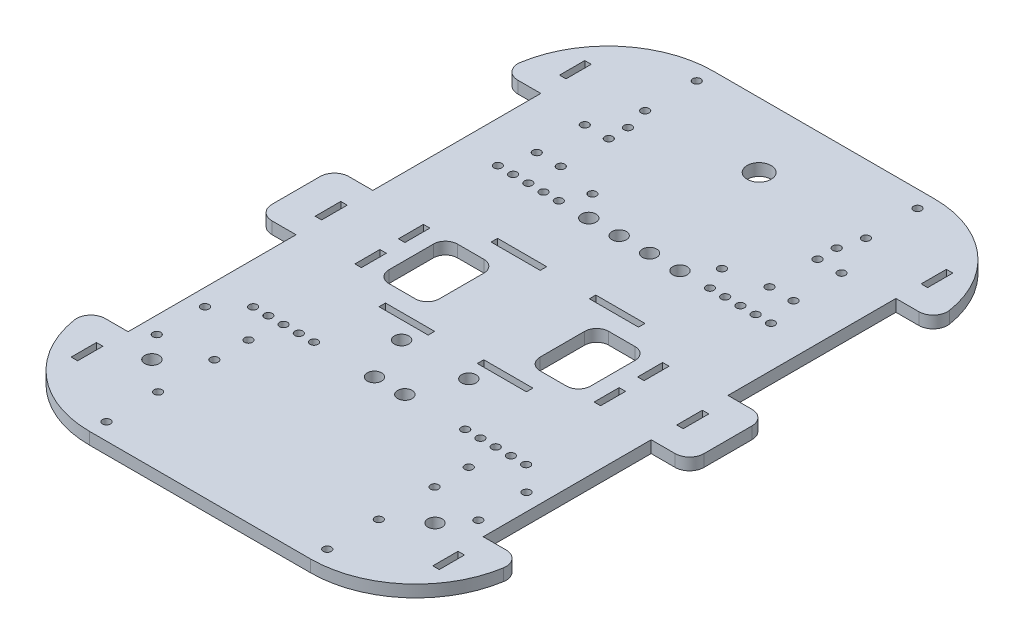
from build123d import *

# Parameters (mm, degrees)
SKETCH2_W           = 2.7
SKETCH2_H           = 10.51
SKETCH2_H_2         = 10.666666666
BOSS_EXTRUDE4_DEPTH = 5
SKETCH5_R           = 1.65
SKETCH5_R_2         = 3
SKETCH5_R_3         = 5
SKETCH5_W           = 20.48
SKETCH5_H           = 2.7
SKETCH5_W_2         = 2.7
SKETCH5_H_2         = 10.42
CUT_EXTRUDE1_DEPTH  = 6


with BuildPart() as part:
    # Sketch2 → Boss-Extrude4 (new body)
    with BuildSketch(Plane(origin=(0, 0, 0), x_dir=(1, 0, 0), z_dir=(0, 1, 0))):
        with BuildLine():
            Line((46, -130), (-46, -130))
            ThreePointArc((-46, -130), (-74.550970119, -119.478980051), (-89.448061775, -92.947368421))
            ThreePointArc((-89.448061775, -92.947368421), (-88.08864154, -88.106685893), (-83.523326079, -86))
            Line((-83.523326079, -86), (-74, -86))
            Line((-74, -86), (-74, -16))
            Line((-74, -16), (-84, -16))
            ThreePointArc((-84, -16), (-88.242640687, -14.242640687), (-90, -10))
            Line((-90, -10), (-90, 10))
            ThreePointArc((-90, 10), (-88.242640687, 14.242640687), (-84, 16))
            Line((-84, 16), (-74, 16))
            Line((-74, 16), (-74, 86))
            Line((-74, 86), (-83.523326079, 86))
            ThreePointArc((-83.523326079, 86), (-88.08864154, 88.106685893), (-89.448061775, 92.947368421))
            ThreePointArc((-89.448061775, 92.947368421), (-74.550970119, 119.478980051), (-46, 130))
            Line((-46, 130), (46, 130))
            ThreePointArc((46, 130), (74.550970119, 119.478980051), (89.448061775, 92.947368421))
            ThreePointArc((89.448061775, 92.947368421), (88.08864154, 88.106685893), (83.523326079, 86))
            Line((83.523326079, 86), (74, 86))
            Line((74, 86), (74, 16))
            Line((74, 16), (84, 16))
            ThreePointArc((84, 16), (88.242640687, 14.242640687), (90, 10))
            Line((90, 10), (90, -10))
            ThreePointArc((90, -10), (88.242640687, -14.242640687), (84, -16))
            Line((84, -16), (74, -16))
            Line((74, -16), (74, -86))
            Line((74, -86), (83.523326079, -86))
            ThreePointArc((83.523326079, -86), (88.08864154, -88.106685893), (89.448061775, -92.947368421))
            ThreePointArc((89.448061775, -92.947368421), (74.550970119, -119.478980051), (46, -130))
        make_face()
        with Locations((-75.35, 101.765)):
            Rectangle(SKETCH2_W, SKETCH2_H, mode=Mode.SUBTRACT)
        with Locations((75.35, 101.765)):
            Rectangle(SKETCH2_W, SKETCH2_H, mode=Mode.SUBTRACT)
        with Locations((75.35, -101.765)):
            Rectangle(SKETCH2_W, SKETCH2_H, mode=Mode.SUBTRACT)
        with Locations((-75.35, -101.765)):
            Rectangle(SKETCH2_W, SKETCH2_H, mode=Mode.SUBTRACT)
        with Locations((-75.35, 0)):
            Rectangle(SKETCH2_W, SKETCH2_H_2, mode=Mode.SUBTRACT)
        with Locations((75.35, 0)):
            Rectangle(SKETCH2_W, SKETCH2_H_2, mode=Mode.SUBTRACT)
    extrude(amount=BOSS_EXTRUDE4_DEPTH)

    # Sketch5 → Cut-Extrude1 (cut, through all)
    with BuildSketch(Plane(origin=(0, 5, 0), x_dir=(1, 0, 0), z_dir=(0, 1, 0))):
        with Locations((-56.9, -51)):
            Circle(SKETCH5_R)
        with Locations((-50.55, -51)):
            Circle(SKETCH5_R)
        with Locations((-44.2, -51)):
            Circle(SKETCH5_R)
        with Locations((-37.85, -51)):
            Circle(SKETCH5_R)
        with Locations((-31.5, -51)):
            Circle(SKETCH5_R)
        with Locations((31.5, -51)):
            Circle(SKETCH5_R)
        with Locations((37.85, -51)):
            Circle(SKETCH5_R)
        with Locations((44.2, -51)):
            Circle(SKETCH5_R)
        with Locations((50.55, -51)):
            Circle(SKETCH5_R)
        with Locations((56.9, -51)):
            Circle(SKETCH5_R)
        with Locations((56.9, 51)):
            Circle(SKETCH5_R)
        with Locations((50.55, 51)):
            Circle(SKETCH5_R)
        with Locations((44.2, 51)):
            Circle(SKETCH5_R)
        with Locations((37.85, 51)):
            Circle(SKETCH5_R)
        with Locations((31.5, 51)):
            Circle(SKETCH5_R)
        with Locations((-31.5, 51)):
            Circle(SKETCH5_R)
        with Locations((-37.85, 51)):
            Circle(SKETCH5_R)
        with Locations((-44.2, 51)):
            Circle(SKETCH5_R)
        with Locations((-50.55, 51)):
            Circle(SKETCH5_R)
        with Locations((-56.9, 51)):
            Circle(SKETCH5_R)
        with Locations((-14, -32)):
            Circle(SKETCH5_R_2)
        with Locations((14, -32)):
            Circle(SKETCH5_R_2)
        with Locations((19, 51)):
            Circle(SKETCH5_R_2)
        with Locations((-19, 51)):
            Circle(SKETCH5_R_2)
        with Locations((-53.5, 83.83)):
            Circle(SKETCH5_R)
        with Locations((-53.5, 63.83)):
            Circle(SKETCH5_R)
        with Locations((-43.5, 63.83)):
            Circle(SKETCH5_R)
        with Locations((-43.5, 83.83)):
            Circle(SKETCH5_R)
        with Locations((43.5, 63.83)):
            Circle(SKETCH5_R)
        with Locations((53.5, 63.83)):
            Circle(SKETCH5_R)
        with Locations((43.5, 83.83)):
            Circle(SKETCH5_R)
        with Locations((53.5, 83.83)):
            Circle(SKETCH5_R)
        with Locations((-46, 123)):
            Circle(SKETCH5_R)
        with Locations((-46, 101.5)):
            Circle(SKETCH5_R)
        with Locations((46, 101.5)):
            Circle(SKETCH5_R)
        with Locations((46, 123)):
            Circle(SKETCH5_R)
        with Locations((-67, -60.960027583)):
            Circle(SKETCH5_R)
        with Locations((-45.897115189, -63.923125828)):
            Circle(SKETCH5_R)
        with Locations((-67, -81.039972417)):
            Circle(SKETCH5_R)
        with Locations((-45.897115189, -78.156819007)):
            Circle(SKETCH5_R)
        with Locations((45.897115189, -63.923125828)):
            Circle(SKETCH5_R)
        with Locations((45.897115189, -78.156819007)):
            Circle(SKETCH5_R)
        with Locations((67, -81.039972417)):
            Circle(SKETCH5_R)
        with Locations((67, -60.960027583)):
            Circle(SKETCH5_R)
        with Locations((46, -123)):
            Circle(SKETCH5_R)
        with Locations((46, -101.5)):
            Circle(SKETCH5_R)
        with Locations((-46, -101.5)):
            Circle(SKETCH5_R)
        with Locations((-46, -123)):
            Circle(SKETCH5_R)
        with Locations((-27, 60.5)):
            Circle(SKETCH5_R)
        with Locations((27, 60.5)):
            Circle(SKETCH5_R)
        with Locations((-43.5, 91.83)):
            Circle(SKETCH5_R)
        with Locations((43.5, 91.83)):
            Circle(SKETCH5_R)
        with Locations((-6.333333333, 51)):
            Circle(SKETCH5_R_2)
        with Locations((6.333333333, 51)):
            Circle(SKETCH5_R_2)
        with Locations((0, 103)):
            Circle(SKETCH5_R_3)
        with Locations((59, -91.08)):
            Circle(SKETCH5_R_2)
        with Locations((-59, -91.08)):
            Circle(SKETCH5_R_2)
        with Locations((-6.333333333, -51)):
            Circle(SKETCH5_R_2)
        with Locations((6.333333333, -51)):
            Circle(SKETCH5_R_2)
        with Locations((20.48, -23.35)):
            Rectangle(SKETCH5_W, SKETCH5_H)
        with Locations((-20.48, -23.35)):
            Rectangle(SKETCH5_W, SKETCH5_H)
        with Locations((20.48, 23.35)):
            Rectangle(SKETCH5_W, SKETCH5_H)
        with Locations((-20.48, 23.35)):
            Rectangle(SKETCH5_W, SKETCH5_H)
        with Locations((49.85, -9.07)):
            Rectangle(SKETCH5_W_2, SKETCH5_H_2)
        with Locations((49.85, 9.07)):
            Rectangle(SKETCH5_W_2, SKETCH5_H_2)
        with Locations((-49.85, 9.07)):
            Rectangle(SKETCH5_W_2, SKETCH5_H_2)
        with Locations((-49.85, -9.07)):
            Rectangle(SKETCH5_W_2, SKETCH5_H_2)
        with BuildLine():
            Line((37.006010734, 14.28), (26.003005367, 14.28))
            ThreePointArc((26.003005367, 14.28), (22.467471461, 12.815533906), (21.003005367, 9.28))
            Line((21.003005367, 9.28), (21.003005367, -7.14))
            Line((21.003005367, -7.14), (21.003005367, -9.28))
            ThreePointArc((21.003005367, -9.28), (22.467471461, -12.815533906), (26.003005367, -14.28))
            Line((26.003005367, -14.28), (37.006010734, -14.28))
            ThreePointArc((37.006010734, -14.28), (40.54154464, -12.815533906), (42.006010734, -9.28))
            Line((42.006010734, -9.28), (42.006010734, 9.28))
            ThreePointArc((42.006010734, 9.28), (40.54154464, 12.815533906), (37.006010734, 14.28))
        make_face()
        with BuildLine():
            Line((-42.006010734, 9.28), (-42.006010734, -9.28))
            ThreePointArc((-42.006010734, -9.28), (-40.54154464, -12.815533906), (-37.006010734, -14.28))
            Line((-37.006010734, -14.28), (-26.003005367, -14.28))
            ThreePointArc((-26.003005367, -14.28), (-22.467471461, -12.815533906), (-21.003005367, -9.28))
            Line((-21.003005367, -9.28), (-21.003005367, 9.28))
            ThreePointArc((-21.003005367, 9.28), (-22.467471461, 12.815533906), (-26.003005367, 14.28))
            Line((-26.003005367, 14.28), (-37.006010734, 14.28))
            ThreePointArc((-37.006010734, 14.28), (-40.54154464, 12.815533906), (-42.006010734, 9.28))
        make_face()
    extrude(amount=-CUT_EXTRUDE1_DEPTH, mode=Mode.SUBTRACT)


solid = part.part
